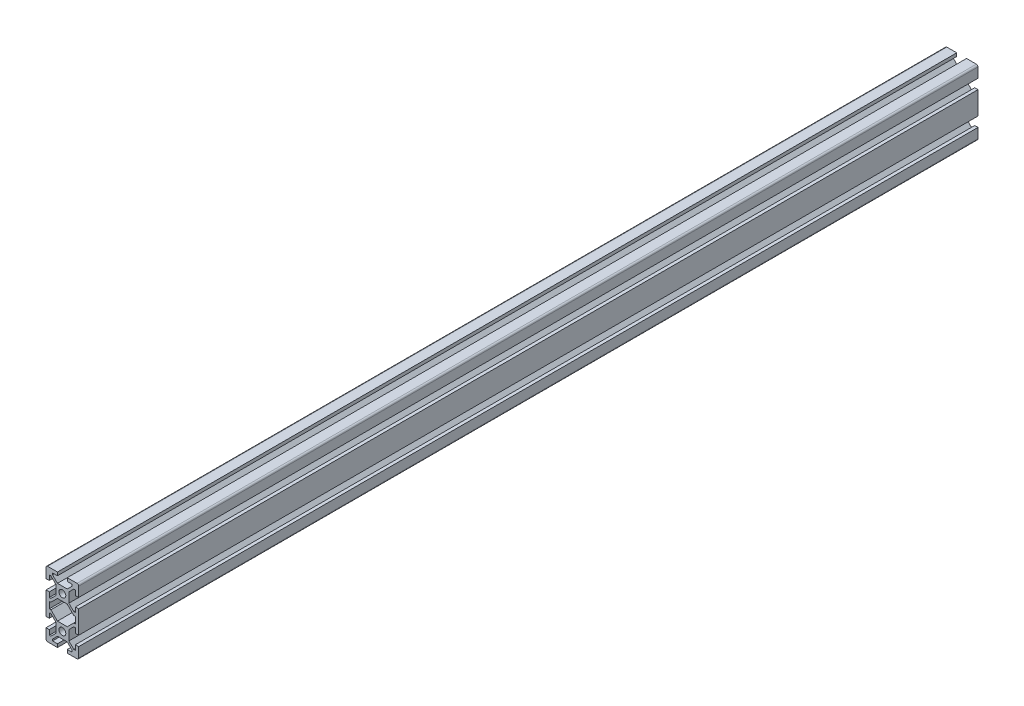
from build123d import *

# Parameters (mm, degrees)
SCHIZZO1_R                   = 2.1
ESTRUSIONE_ESTRUSIONE1_DEPTH = 550
RACCORDO1_R                  = 1


with BuildPart() as part:
    # Schizzo1 → Estrusione-Estrusione1 (new body)
    with BuildSketch(Plane.XY):
        Polygon((-3, 20), (-10, 20), (-10, 13), (-8, 13), (-8, 16), (-7, 16), (-4, 13), (-4, 7), (-7, 4), (-8, 4), (-8, 7), (-10, 7), (-10, -7), (-8, -7), (-8, -4), (-7, -4), (-4, -7), (-4, -13), (-7, -16), (-8, -16), (-8, -13), (-10, -13), (-10, -20), (-3, -20), (-3, -18), (-6, -18), (-6, -17), (-3, -14), (3, -14), (6, -17), (6, -18), (3, -18), (3, -20), (10, -20), (10, -13), (8, -13), (8, -16), (7, -16), (4, -13), (4, -7), (7, -4), (8, -4), (8, -7), (10, -7), (10, 7), (8, 7), (8, 4), (7, 4), (4, 7), (4, 13), (7, 16), (8, 16), (8, 13), (10, 13), (10, 20), (3, 20), (3, 18), (6, 18), (6, 17), (3, 14), (-3, 14), (-6, 17), (-6, 18), (-3, 18), align=None)
        Polygon((8, 2), (8, -2), (7, -2), (3, -6), (-3, -6), (-7, -2), (-8, -2), (-8, 2), (-7, 2), (-3, 6), (3, 6), (7, 2), align=None, mode=Mode.SUBTRACT)
        with Locations((0, 10)):
            Circle(SCHIZZO1_R, mode=Mode.SUBTRACT)
        with Locations((0, -10)):
            Circle(SCHIZZO1_R, mode=Mode.SUBTRACT)
    extrude(amount=ESTRUSIONE_ESTRUSIONE1_DEPTH)

    # Raccordo1
    raccordo1_edges = [part.edges().sort_by_distance(p)[0] for p in [
        (-10, 20, 275),
        (10, 20, 275),
        (10, -20, 275),
        (-10, -20, 275),
    ]]
    fillet(raccordo1_edges, radius=RACCORDO1_R)


solid = part.part
